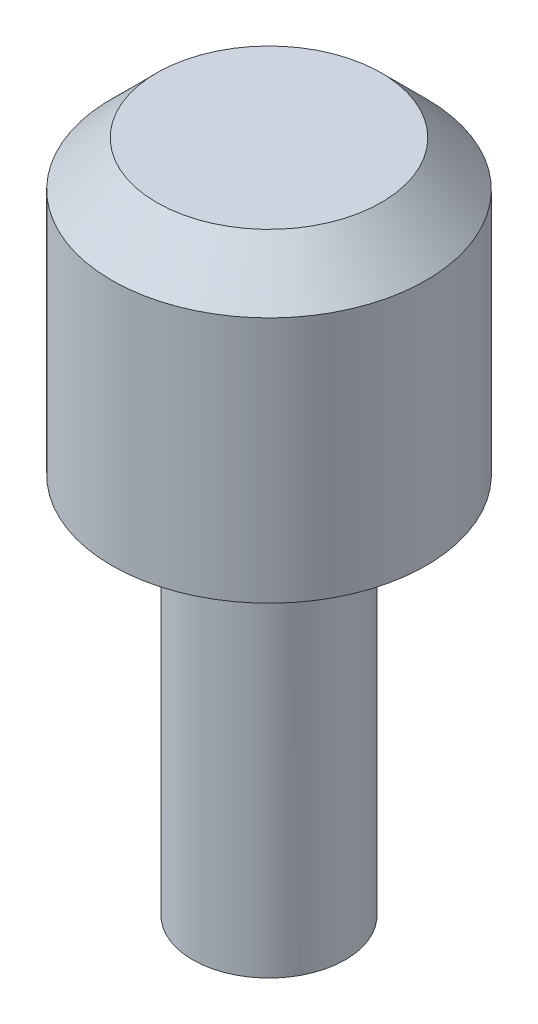
from build123d import *

# Parameters (mm, degrees)
SKETCH1_R           = 3.5
BOSS_EXTRUDE1_DEPTH = 6.5
CHAMFER1_SIZE       = 1
SKETCH2_R           = 1.7
BOSS_EXTRUDE2_DEPTH = 8.5


with BuildPart() as part:
    # Sketch1 → Boss-Extrude1 (new body)
    with BuildSketch(Plane(origin=(0, 0, 0), x_dir=(1, 0, 0), z_dir=(0, 1, 0))):
        Circle(SKETCH1_R)
    extrude(amount=BOSS_EXTRUDE1_DEPTH)

    # Chamfer1
    chamfer1_edges = [part.edges().sort_by_distance(p)[0] for p in [
        (-3.5, 6.5, 0),
    ]]
    chamfer(chamfer1_edges, length=CHAMFER1_SIZE)

    # Sketch2 → Boss-Extrude2 (add)
    with BuildSketch(Plane.XZ):
        Circle(SKETCH2_R)
    extrude(amount=BOSS_EXTRUDE2_DEPTH)


solid = part.part
